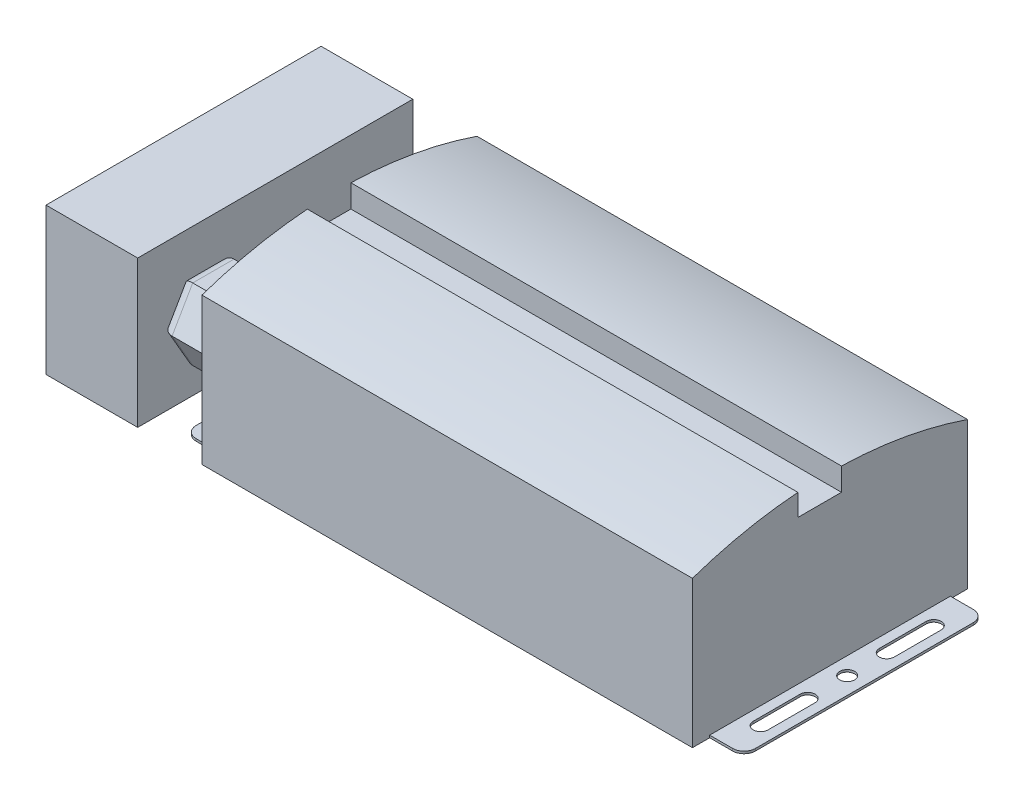
from build123d import *

# Parameters (mm, degrees)
EXTRUDE_1_DEPTH = 214
EXTRUDE_2_DEPTH = 23
EXTRUDE_3_DEPTH = 28
FILLET_1_R      = 5
SKETCH_4_W      = 244
SKETCH_4_H      = 105
SKETCH_4_R      = 3.25
EXTRUDE_4_DEPTH = 1
FILLET_2_R      = 5
SKETCH_5_W      = 120
SKETCH_5_H      = 64
EXTRUDE_5_DEPTH = 40


with BuildPart() as part:
    # Эскиз1 → Бобышка-Вытянуть1 (new body)
    with BuildSketch(Plane(origin=(0, 0, 0), x_dir=(0, 0, -1), z_dir=(1, 0, 0))):
        with BuildLine():
            Line((-60, 0), (60, 0))
            Line((60, 0), (60, 64))
            ThreePointArc((60, 64), (32.877245052, 71.055175037), (5, 73.932420089))
            Line((5, 73.932420089), (5, 64))
            Line((5, 64), (-14, 64))
            Line((-14, 64), (-14, 73.469509676))
            ThreePointArc((-14, 73.469509676), (-37.301714483, 70.200392098), (-60, 64))
            Line((-60, 64), (-60, 0))
        make_face()
    extrude(amount=EXTRUDE_1_DEPTH)

    # Эскиз2 → Бобышка-Вытянуть2 (add)
    with BuildSketch(Plane.ZY):
        Polygon((-19, 32), (-25.25, 42.825317547), (-37.75, 42.825317547), (-44, 32), (-37.75, 21.174682453), (-25.25, 21.174682453), align=None)
    extrude(amount=EXTRUDE_2_DEPTH)

    # Эскиз2<3> → Бобышка-Вытянуть3 (add)
    with BuildSketch(Plane.ZY):
        Polygon((50, 32), (41, 47.588457268), (23, 47.588457268), (14, 32), (23, 16.411542732), (41, 16.411542732), align=None)
    extrude(amount=EXTRUDE_3_DEPTH)

    # Скругление1
    fillet_1_edges = [part.edges().sort_by_distance(p)[0] for p in [
        (-28, 24.205771366, 45.5),
        (-28, 16.411542732, 32),
        (-28, 24.205771366, 18.5),
        (-28, 39.794228634, 18.5),
        (-28, 47.588457268, 32),
        (-28, 39.794228634, 45.5),
        (-23, 26.587341226, -40.875),
        (-23, 21.174682453, -31.5),
        (-23, 26.587341226, -22.125),
        (-23, 37.412658774, -22.125),
        (-23, 42.825317547, -31.5),
        (-23, 37.412658774, -40.875),
    ]]
    fillet(fillet_1_edges, radius=FILLET_1_R)

    # Эскиз4 → Бобышка-Вытянуть4 (add)
    with BuildSketch(Plane.XZ):
        with Locations((107, 0)):
            Rectangle(SKETCH_4_W, SKETCH_4_H)
        with Locations((221.5, 0)):
            Circle(SKETCH_4_R, mode=Mode.SUBTRACT)
        with Locations((-7.5, 0)):
            Circle(SKETCH_4_R, mode=Mode.SUBTRACT)
        with BuildLine():
            Line((224.75, 37.75), (224.75, 17.25))
            ThreePointArc((224.75, 17.25), (221.5, 14), (218.25, 17.25))
            Line((218.25, 17.25), (218.25, 37.75))
            ThreePointArc((218.25, 37.75), (221.5, 41), (224.75, 37.75))
        make_face(mode=Mode.SUBTRACT)
        with BuildLine():
            Line((224.75, -37.75), (224.75, -17.25))
            ThreePointArc((224.75, -17.25), (221.5, -14), (218.25, -17.25))
            Line((218.25, -17.25), (218.25, -37.75))
            ThreePointArc((218.25, -37.75), (221.5, -41), (224.75, -37.75))
        make_face(mode=Mode.SUBTRACT)
        with BuildLine():
            Line((-10.75, 37.75), (-10.75, 17.25))
            ThreePointArc((-10.75, 17.25), (-7.5, 14), (-4.25, 17.25))
            Line((-4.25, 17.25), (-4.25, 37.75))
            ThreePointArc((-4.25, 37.75), (-7.5, 41), (-10.75, 37.75))
        make_face(mode=Mode.SUBTRACT)
        with BuildLine():
            Line((-10.75, -37.75), (-10.75, -17.25))
            ThreePointArc((-10.75, -17.25), (-7.5, -14), (-4.25, -17.25))
            Line((-4.25, -17.25), (-4.25, -37.75))
            ThreePointArc((-4.25, -37.75), (-7.5, -41), (-10.75, -37.75))
        make_face(mode=Mode.SUBTRACT)
    extrude(amount=-EXTRUDE_4_DEPTH)

    # Скругление2
    fillet_2_edges = [part.edges().sort_by_distance(p)[0] for p in [
        (-15, 0.5, -52.5),
        (-15, 0.5, 52.5),
        (229, 0.5, -52.5),
        (229, 0.5, 52.5),
    ]]
    fillet(fillet_2_edges, radius=FILLET_2_R)

    # Эскиз5 → Бобышка-Вытянуть5 (add)
    with BuildSketch(Plane.ZY.offset(28)):
        with Locations((0, 32)):
            Rectangle(SKETCH_5_W, SKETCH_5_H)
    extrude(amount=EXTRUDE_5_DEPTH)


solid = part.part
